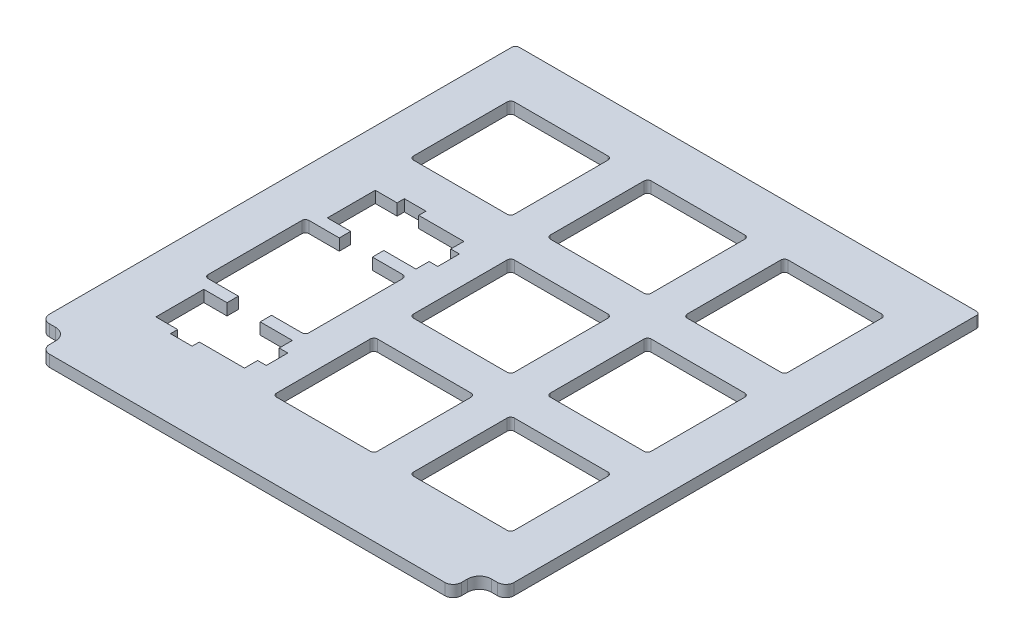
from build123d import *

# Parameters (mm, degrees)
EXTRUDE_1_DEPTH                = 1.6
SKETCH_2_W                     = 14
SKETCH_2_H                     = 14
CUT_EXTRUDE_1_DEPTH            = 1.6
FILLET_1_R                     = 0.5
PATTERN_LINEAR_2_COUNT         = 3
PATTERN_LINEAR_2_PITCH         = 19
PATTERN_LINEAR_2_COUNT_DIR2    = 3
PATTERN_LINEAR_2_PITCH_DIR2    = 19
FILLET_1_OF_PATTERN_LINEAR_2_R = 0.5
CUT_EXTRUDE_3_DEPTH            = 1.6
FILLET_2_R                     = 0.5


with BuildPart() as part:
    # 草图1 → 凸台-拉伸1 (new body)
    with BuildSketch(Plane(origin=(0, 0, 0), x_dir=(1, 0, 0), z_dir=(0, 1, 0))):
        with BuildLine():
            Line((-12.500806884, 61.22832279), (51.999193116, 61.22832279))
            Line((51.999193116, 61.22832279), (51.999193116, -3.47167721))
            ThreePointArc((51.999193116, -3.47167721), (51.662365914, -4.284850009), (50.849193116, -4.62167721))
            Line((50.849193116, -4.62167721), (49.999193116, -4.62167721))
            ThreePointArc((49.999193116, -4.62167721), (48.832466927, -5.104951021), (48.349193116, -6.27167721))
            Line((48.349193116, -6.27167721), (48.349193116, -7.12167721))
            ThreePointArc((48.349193116, -7.12167721), (48.012365914, -7.934850009), (47.199193116, -8.27167721))
            Line((47.199193116, -8.27167721), (-7.700806884, -8.27167721))
            ThreePointArc((-7.700806884, -8.27167721), (-8.513979683, -7.934850009), (-8.850806884, -7.12167721))
            Line((-8.850806884, -7.12167721), (-8.850806884, -6.27167721))
            ThreePointArc((-8.850806884, -6.27167721), (-9.334080695, -5.104951021), (-10.500806884, -4.62167721))
            Line((-10.500806884, -4.62167721), (-11.350806884, -4.62167721))
            ThreePointArc((-11.350806884, -4.62167721), (-12.163979683, -4.284850009), (-12.500806884, -3.47167721))
            Line((-12.500806884, -3.47167721), (-12.500806884, 61.22832279))
        make_face()
    extrude(amount=EXTRUDE_1_DEPTH)

    # 草图2 → 切除-拉伸1 (cut)
    with BuildSketch(Plane.XZ):
        with Locations((38.749193116, -9.315811453)):
            Rectangle(SKETCH_2_W, SKETCH_2_H)
    cut_extrude_1 = extrude(amount=-CUT_EXTRUDE_1_DEPTH, mode=Mode.SUBTRACT)

    # 圆角1
    fillet_1_edges = [part.edges().sort_by_distance(p)[0] for p in [
        (31.749193116, 0.8, -16.315811453),
        (31.749193116, 0.8, -2.315811453),
        (45.749193116, 0.8, -2.315811453),
        (45.749193116, 0.8, -16.315811453),
    ]]
    fillet(fillet_1_edges, radius=FILLET_1_R)

    # 阵列(线性)2: Cut-Extrude 1 3 × 3, 2 skipped
    with Locations(*[(-j * PATTERN_LINEAR_2_PITCH_DIR2, 0, -i * PATTERN_LINEAR_2_PITCH) for i in range(PATTERN_LINEAR_2_COUNT) for j in range(PATTERN_LINEAR_2_COUNT_DIR2) if (i, j) not in ((0, 0), (0, 2), (1, 2))]):
        add(cut_extrude_1, mode=Mode.SUBTRACT)

    # 圆角1 of 阵列(线性)2
    fillet_1_of_pattern_linear_2_edges = [part.edges().sort_by_distance(p)[0] for p in [
        (12.749193116, 0.8, -16.315811453),
        (12.749193116, 0.8, -2.315811453),
        (26.749193116, 0.8, -2.315811453),
        (26.749193116, 0.8, -16.315811453),
        (31.749193116, 0.8, -35.315811453),
        (31.749193116, 0.8, -21.315811453),
        (45.749193116, 0.8, -21.315811453),
        (45.749193116, 0.8, -35.315811453),
        (12.749193116, 0.8, -35.315811453),
        (12.749193116, 0.8, -21.315811453),
        (26.749193116, 0.8, -21.315811453),
        (26.749193116, 0.8, -35.315811453),
        (31.749193116, 0.8, -54.315811453),
        (31.749193116, 0.8, -40.315811453),
        (45.749193116, 0.8, -40.315811453),
        (45.749193116, 0.8, -54.315811453),
        (12.749193116, 0.8, -54.315811453),
        (12.749193116, 0.8, -40.315811453),
        (26.749193116, 0.8, -40.315811453),
        (26.749193116, 0.8, -54.315811453),
        (-6.250806884, 0.8, -54.315811453),
        (-6.250806884, 0.8, -40.315811453),
        (7.749193116, 0.8, -40.315811453),
        (7.749193116, 0.8, -54.315811453),
    ]]
    fillet(fillet_1_of_pattern_linear_2_edges, radius=FILLET_1_OF_PATTERN_LINEAR_2_R)

    # 草图3 → 切除-拉伸3 (cut)
    with BuildSketch(Plane(origin=(0, 1.6, 0), x_dir=(1, 0, 0), z_dir=(0, 1, 0))):
        with BuildLine():
            Line((-6.250806884, 12.315811453), (-6.250806884, 25.315811453))
            ThreePointArc((-6.250806884, 25.315811453), (-6.104360275, 25.669364844), (-5.750806884, 25.815811453))
            Line((-5.750806884, 25.815811453), (-1.550806884, 25.815811453))
            Line((-1.550806884, 25.815811453), (-1.550806884, 27.395811453))
            Line((-1.550806884, 27.395811453), (-4.780806884, 27.395811453))
            Line((-4.780806884, 27.395811453), (-4.780806884, 34.045811453))
            Line((-4.780806884, 34.045811453), (-1.750806884, 34.045811453))
            Line((-1.750806884, 34.045811453), (-1.750806884, 35.045811453))
            Line((-1.750806884, 35.045811453), (1.249193116, 35.045811453))
            Line((1.249193116, 35.045811453), (1.249193116, 34.045811453))
            Line((1.249193116, 34.045811453), (7.519193116, 34.045811453))
            Line((7.519193116, 34.045811453), (7.519193116, 32.220811453))
            Line((7.519193116, 32.220811453), (8.719193116, 32.220811453))
            Line((8.719193116, 32.220811453), (8.719193116, 29.220811453))
            Line((8.719193116, 29.220811453), (7.519193116, 29.220811453))
            Line((7.519193116, 29.220811453), (7.519193116, 27.395811453))
            Line((7.519193116, 27.395811453), (3.049193116, 27.395811453))
            Line((3.049193116, 27.395811453), (3.049193116, 25.815811453))
            Line((3.049193116, 25.815811453), (7.249193116, 25.815811453))
            ThreePointArc((7.249193116, 25.815811453), (7.602746506, 25.669364844), (7.749193116, 25.315811453))
            Line((7.749193116, 25.315811453), (7.749193116, 12.315811453))
            ThreePointArc((7.749193116, 12.315811453), (7.602746506, 11.962258063), (7.249193116, 11.815811453))
            Line((7.249193116, 11.815811453), (3.049193116, 11.815811453))
            Line((3.049193116, 11.815811453), (3.049193116, 10.235811453))
            Line((3.049193116, 10.235811453), (7.519193116, 10.235811453))
            Line((7.519193116, 10.235811453), (7.519193116, 8.410811453))
            Line((7.519193116, 8.410811453), (8.719193116, 8.410811453))
            Line((8.719193116, 8.410811453), (8.719193116, 5.410811453))
            Line((8.719193116, 5.410811453), (7.519193116, 5.410811453))
            Line((7.519193116, 5.410811453), (7.519193116, 3.585811453))
            Line((7.519193116, 3.585811453), (1.249193116, 3.585811453))
            Line((1.249193116, 3.585811453), (1.249193116, 2.585811453))
            Line((1.249193116, 2.585811453), (-1.750806884, 2.585811453))
            Line((-1.750806884, 2.585811453), (-1.750806884, 3.585811453))
            Line((-1.750806884, 3.585811453), (-4.780806884, 3.585811453))
            Line((-4.780806884, 3.585811453), (-4.780806884, 10.235811453))
            Line((-4.780806884, 10.235811453), (-1.550806884, 10.235811453))
            Line((-1.550806884, 10.235811453), (-1.550806884, 11.815811453))
            Line((-1.550806884, 11.815811453), (-5.750806884, 11.815811453))
            ThreePointArc((-5.750806884, 11.815811453), (-6.104360275, 11.962258063), (-6.250806884, 12.315811453))
        make_face()
    extrude(amount=-CUT_EXTRUDE_3_DEPTH, mode=Mode.SUBTRACT)

    # 圆角2
    fillet_2_edges = [part.edges().sort_by_distance(p)[0] for p in [
        (-12.500806884, 0.8, -61.22832279),
        (51.999193116, 0.8, -61.22832279),
    ]]
    fillet(fillet_2_edges, radius=FILLET_2_R)


solid = part.part
